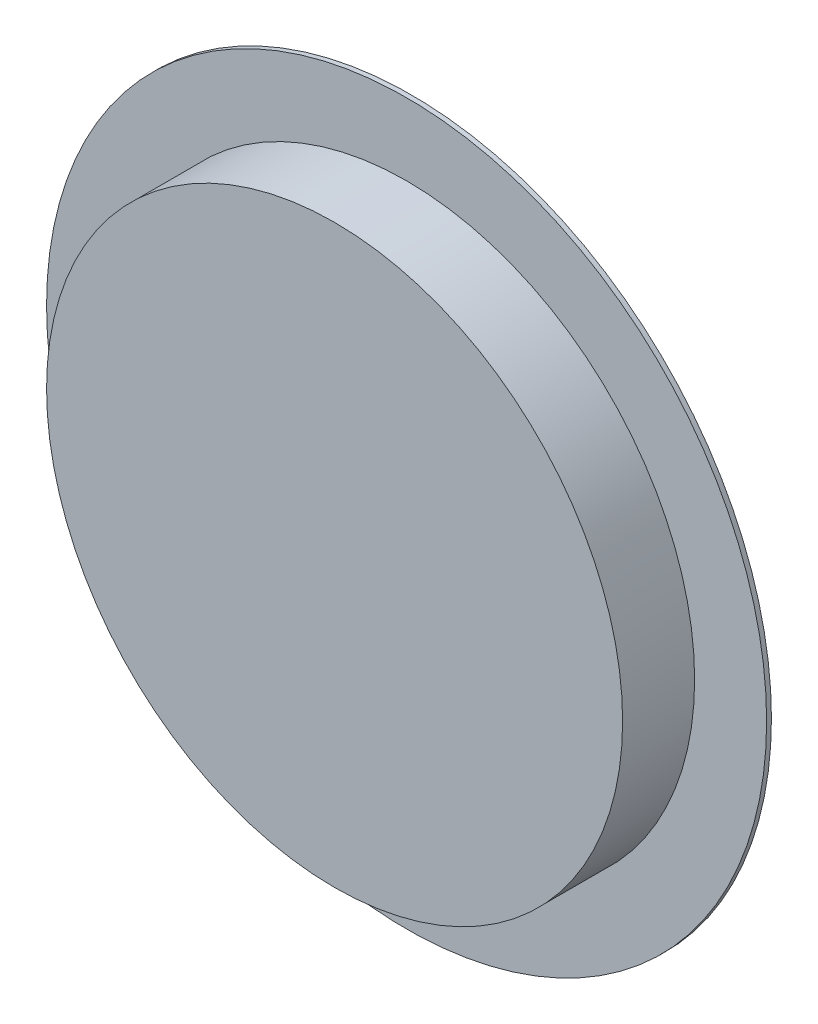
from build123d import *

# Parameters (mm, degrees)
SKETCH1_R           = 75
BOSS_EXTRUDE1_DEPTH = 1
SKETCH2_R           = 60
BOSS_EXTRUDE2_DEPTH = 15


with BuildPart() as part:
    # Sketch1 → Boss-Extrude1 (new body)
    with BuildSketch(Plane.XY):
        Circle(SKETCH1_R)
    extrude(amount=BOSS_EXTRUDE1_DEPTH)

    # Sketch2 → Boss-Extrude2 (add)
    with BuildSketch(Plane.XY.offset(1)):
        Circle(SKETCH2_R)
    extrude(amount=BOSS_EXTRUDE2_DEPTH)


solid = part.part
